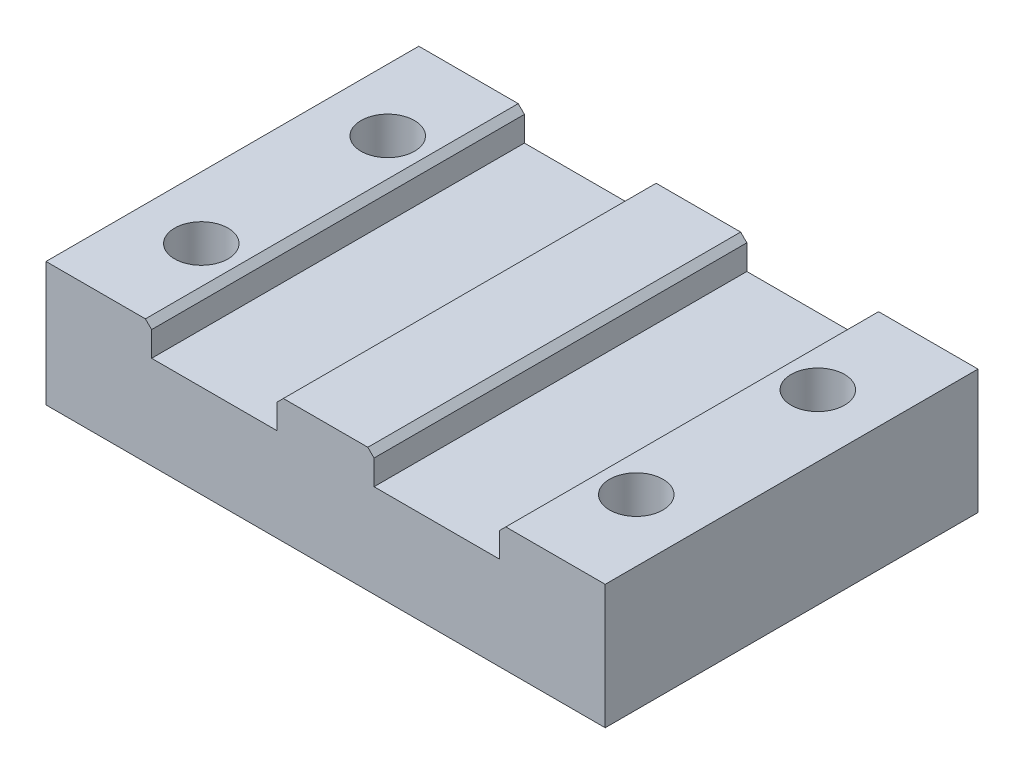
from build123d import *

# Parameters (mm, degrees)
SKETCH1_W           = 90
SKETCH1_H           = 60
BOSS_EXTRUDE1_DEPTH = 20
CUT_EXTRUDE1_DEPTH  = 61
SKETCH3_R           = 4.3
CUT_EXTRUDE2_DEPTH  = 21
SKETCH4_R           = 8.8
CUT_EXTRUDE3_DEPTH  = 10
CHAMFER1_SIZE       = 1


with BuildPart() as part:
    # Sketch1 → Boss-Extrude1 (new body)
    with BuildSketch(Plane(origin=(0, 0, 0), x_dir=(1, 0, 0), z_dir=(0, 1, 0))):
        Rectangle(SKETCH1_W, SKETCH1_H)
    extrude(amount=BOSS_EXTRUDE1_DEPTH)

    # Sketch2 → Cut-Extrude1 (cut, through all)
    with BuildSketch(Plane.XY.offset(30)):
        Polygon((28, 25), (-28, 25), (-28, 15), (-7.8, 15), (-7.8, 20), (7.8, 20), (7.8, 15), (28, 15), align=None)
    extrude(amount=-CUT_EXTRUDE1_DEPTH, mode=Mode.SUBTRACT)

    # Sketch3 → Cut-Extrude2 (cut, through all)
    with BuildSketch(Plane.XZ):
        with Locations((-35, 15)):
            Circle(SKETCH3_R)
        with Locations((-35, -15)):
            Circle(SKETCH3_R)
        with Locations((35, -14.217273236)):
            Circle(SKETCH3_R)
        with Locations((35, 15)):
            Circle(SKETCH3_R)
    extrude(amount=-CUT_EXTRUDE2_DEPTH, mode=Mode.SUBTRACT)

    # Sketch4 → Cut-Extrude3 (cut)
    with BuildSketch(Plane.XZ):
        with Locations((35, 15)):
            Circle(SKETCH4_R)
        with Locations((35, -14.217273236)):
            Circle(SKETCH4_R)
        with Locations((-35, 15)):
            Circle(SKETCH4_R)
        with Locations((-35, -15)):
            Circle(SKETCH4_R)
    extrude(amount=-CUT_EXTRUDE3_DEPTH, mode=Mode.SUBTRACT)

    # Chamfer1
    chamfer1_edges = [part.edges().sort_by_distance(p)[0] for p in [
        (28, 20, 0),
        (-28, 20, 0),
        (7.8, 20, 0),
        (-7.8, 20, 0),
    ]]
    chamfer(chamfer1_edges, length=CHAMFER1_SIZE)


solid = part.part
